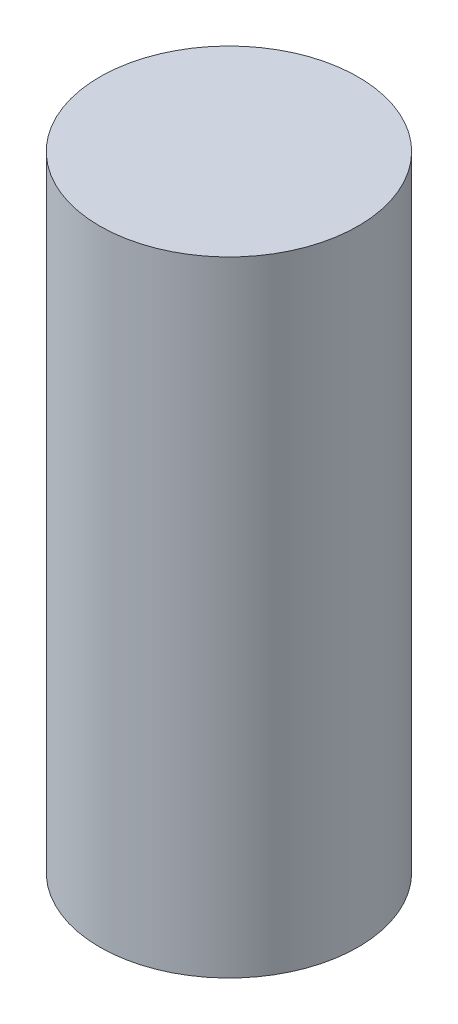
from build123d import *

# Parameters (mm, degrees)
SKETCH1_R           = 6
BOSS_EXTRUDE1_DEPTH = 14.5


with BuildPart() as part:
    # Sketch1 → Boss-Extrude1 (new body, symmetric)
    with BuildSketch(Plane(origin=(0, 0, 0), x_dir=(1, 0, 0), z_dir=(0, 1, 0))):
        Circle(SKETCH1_R)
    extrude(amount=BOSS_EXTRUDE1_DEPTH, both=True)


solid = part.part
